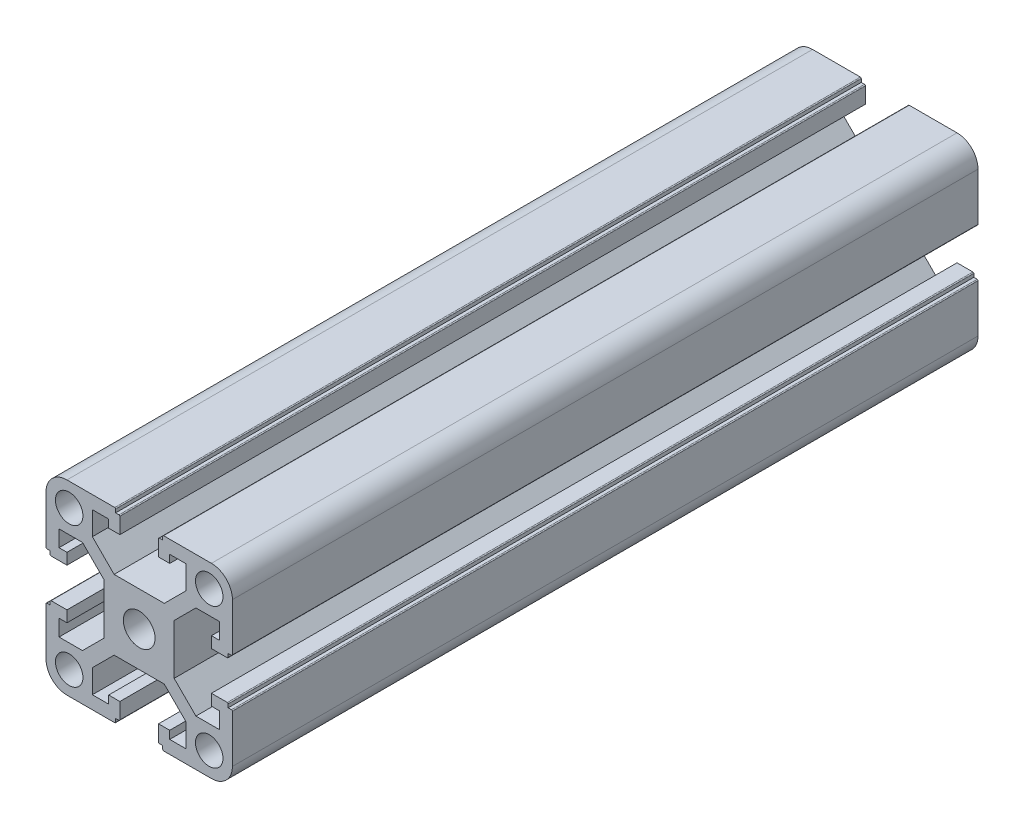
from build123d import *

# Parameters (mm, degrees)
SKETCH_1_R      = 2.95
SKETCH_1_R_2    = 3.4
EXTRUDE_1_DEPTH = 80


with BuildPart() as part:
    # 草图1 → 凸台-拉伸1 (new body, symmetric)
    with BuildSketch(Plane.XY.offset(50)):
        with BuildLine():
            Line((-1518.245004392, 3588.004280474), (-1518.245004392, 3582.975600817))
            Line((-1518.245004392, 3582.975600817), (-1522.916324736, 3578.304280474))
            Line((-1522.916324736, 3578.304280474), (-1533.673684048, 3578.304280474))
            Line((-1533.673684048, 3578.304280474), (-1538.345004392, 3582.975600817))
            Line((-1538.345004392, 3582.975600817), (-1538.345004392, 3588.004280474))
            Line((-1538.345004392, 3588.004280474), (-1534.845004392, 3588.004280474))
            Line((-1534.845004392, 3588.004280474), (-1534.845004392, 3586.304280474))
            Line((-1534.845004392, 3586.304280474), (-1532.445004392, 3586.304280474))
            Line((-1532.445004392, 3586.304280474), (-1532.445004392, 3589.704280474))
            ThreePointArc((-1532.445004392, 3589.704280474), (-1532.503583036, 3589.84570183), (-1532.645004392, 3589.904280474))
            Line((-1532.645004392, 3589.904280474), (-1533.345004392, 3589.904280474))
            Line((-1533.345004392, 3589.904280474), (-1533.345004392, 3590.604280474))
            ThreePointArc((-1533.345004392, 3590.604280474), (-1533.403583036, 3590.74570183), (-1533.545004392, 3590.804280474))
            Line((-1533.545004392, 3590.804280474), (-1543.795004392, 3590.804280474))
            ThreePointArc((-1543.795004392, 3590.804280474), (-1546.976984907, 3589.486260989), (-1548.295004392, 3586.304280474))
            Line((-1548.295004392, 3586.304280474), (-1548.295004392, 3576.054280474))
            ThreePointArc((-1548.295004392, 3576.054280474), (-1548.236425748, 3575.912859117), (-1548.095004392, 3575.854280474))
            Line((-1548.095004392, 3575.854280474), (-1547.395004392, 3575.854280474))
            Line((-1547.395004392, 3575.854280474), (-1547.395004392, 3575.154280474))
            ThreePointArc((-1547.395004392, 3575.154280474), (-1547.336425748, 3575.012859117), (-1547.195004392, 3574.954280474))
            Line((-1547.195004392, 3574.954280474), (-1543.795004392, 3574.954280474))
            Line((-1543.795004392, 3574.954280474), (-1543.795004392, 3577.354280474))
            Line((-1543.795004392, 3577.354280474), (-1545.495004392, 3577.354280474))
            Line((-1545.495004392, 3577.354280474), (-1545.495004392, 3580.854280474))
            Line((-1545.495004392, 3580.854280474), (-1540.466324736, 3580.854280474))
            Line((-1540.466324736, 3580.854280474), (-1535.795004392, 3576.18296013))
            Line((-1535.795004392, 3576.18296013), (-1535.795004392, 3565.425600817))
            Line((-1535.795004392, 3565.425600817), (-1540.466324736, 3560.754280474))
            Line((-1540.466324736, 3560.754280474), (-1545.495004392, 3560.754280474))
            Line((-1545.495004392, 3560.754280474), (-1545.495004392, 3564.254280474))
            Line((-1545.495004392, 3564.254280474), (-1543.795004392, 3564.254280474))
            Line((-1543.795004392, 3564.254280474), (-1543.795004392, 3566.654280474))
            Line((-1543.795004392, 3566.654280474), (-1547.195004392, 3566.654280474))
            ThreePointArc((-1547.195004392, 3566.654280474), (-1547.336425748, 3566.59570183), (-1547.395004392, 3566.454280474))
            Line((-1547.395004392, 3566.454280474), (-1547.395004392, 3565.754280474))
            Line((-1547.395004392, 3565.754280474), (-1548.095004392, 3565.754280474))
            ThreePointArc((-1548.095004392, 3565.754280474), (-1548.236425748, 3565.69570183), (-1548.295004392, 3565.554280474))
            Line((-1548.295004392, 3565.554280474), (-1548.295004392, 3555.304280474))
            ThreePointArc((-1548.295004392, 3555.304280474), (-1546.976984907, 3552.122299958), (-1543.795004392, 3550.804280474))
            Line((-1543.795004392, 3550.804280474), (-1533.545004392, 3550.804280474))
            ThreePointArc((-1533.545004392, 3550.804280474), (-1533.403583036, 3550.862859117), (-1533.345004392, 3551.004280474))
            Line((-1533.345004392, 3551.004280474), (-1533.345004392, 3551.704280474))
            Line((-1533.345004392, 3551.704280474), (-1532.645004392, 3551.704280474))
            ThreePointArc((-1532.645004392, 3551.704280474), (-1532.503583036, 3551.762859117), (-1532.445004392, 3551.904280474))
            Line((-1532.445004392, 3551.904280474), (-1532.445004392, 3555.304280474))
            Line((-1532.445004392, 3555.304280474), (-1534.845004392, 3555.304280474))
            Line((-1534.845004392, 3555.304280474), (-1534.845004392, 3553.604280474))
            Line((-1534.845004392, 3553.604280474), (-1538.345004392, 3553.604280474))
            Line((-1538.345004392, 3553.604280474), (-1538.345004392, 3558.63296013))
            Line((-1538.345004392, 3558.63296013), (-1533.673684048, 3563.304280474))
            Line((-1533.673684048, 3563.304280474), (-1522.916324736, 3563.304280474))
            Line((-1522.916324736, 3563.304280474), (-1518.245004392, 3558.63296013))
            Line((-1518.245004392, 3558.63296013), (-1518.245004392, 3553.604280474))
            Line((-1518.245004392, 3553.604280474), (-1521.745004392, 3553.604280474))
            Line((-1521.745004392, 3553.604280474), (-1521.745004392, 3555.304280474))
            Line((-1521.745004392, 3555.304280474), (-1524.145004392, 3555.304280474))
            Line((-1524.145004392, 3555.304280474), (-1524.145004392, 3551.904280474))
            ThreePointArc((-1524.145004392, 3551.904280474), (-1524.086425748, 3551.762859117), (-1523.945004392, 3551.704280474))
            Line((-1523.945004392, 3551.704280474), (-1523.245004392, 3551.704280474))
            Line((-1523.245004392, 3551.704280474), (-1523.245004392, 3551.004280474))
            ThreePointArc((-1523.245004392, 3551.004280474), (-1523.186425748, 3550.862859117), (-1523.045004392, 3550.804280474))
            Line((-1523.045004392, 3550.804280474), (-1512.795004392, 3550.804280474))
            ThreePointArc((-1512.795004392, 3550.804280474), (-1509.613023877, 3552.122299958), (-1508.295004392, 3555.304280474))
            Line((-1508.295004392, 3555.304280474), (-1508.295004392, 3565.554280474))
            ThreePointArc((-1508.295004392, 3565.554280474), (-1508.353583036, 3565.69570183), (-1508.495004392, 3565.754280474))
            Line((-1508.495004392, 3565.754280474), (-1509.195004392, 3565.754280474))
            Line((-1509.195004392, 3565.754280474), (-1509.195004392, 3566.454280474))
            ThreePointArc((-1509.195004392, 3566.454280474), (-1509.253583036, 3566.59570183), (-1509.395004392, 3566.654280474))
            Line((-1509.395004392, 3566.654280474), (-1512.795004392, 3566.654280474))
            Line((-1512.795004392, 3566.654280474), (-1512.795004392, 3564.254280474))
            Line((-1512.795004392, 3564.254280474), (-1511.095004392, 3564.254280474))
            Line((-1511.095004392, 3564.254280474), (-1511.095004392, 3560.754280474))
            Line((-1511.095004392, 3560.754280474), (-1516.123684048, 3560.754280474))
            Line((-1516.123684048, 3560.754280474), (-1520.795004392, 3565.425600817))
            Line((-1520.795004392, 3565.425600817), (-1520.795004392, 3576.18296013))
            Line((-1520.795004392, 3576.18296013), (-1516.123684048, 3580.854280474))
            Line((-1516.123684048, 3580.854280474), (-1511.095004392, 3580.854280474))
            Line((-1511.095004392, 3580.854280474), (-1511.095004392, 3577.354280474))
            Line((-1511.095004392, 3577.354280474), (-1512.795004392, 3577.354280474))
            Line((-1512.795004392, 3577.354280474), (-1512.795004392, 3574.954280474))
            Line((-1512.795004392, 3574.954280474), (-1509.395004392, 3574.954280474))
            ThreePointArc((-1509.395004392, 3574.954280474), (-1509.253583036, 3575.012859117), (-1509.195004392, 3575.154280474))
            Line((-1509.195004392, 3575.154280474), (-1509.195004392, 3575.854280474))
            Line((-1509.195004392, 3575.854280474), (-1508.495004392, 3575.854280474))
            ThreePointArc((-1508.495004392, 3575.854280474), (-1508.353583036, 3575.912859117), (-1508.295004392, 3576.054280474))
            Line((-1508.295004392, 3576.054280474), (-1508.295004392, 3586.304280474))
            ThreePointArc((-1508.295004392, 3586.304280474), (-1509.613023877, 3589.486260989), (-1512.795004392, 3590.804280474))
            Line((-1512.795004392, 3590.804280474), (-1523.045004392, 3590.804280474))
            ThreePointArc((-1523.045004392, 3590.804280474), (-1523.186425748, 3590.74570183), (-1523.245004392, 3590.604280474))
            Line((-1523.245004392, 3590.604280474), (-1523.245004392, 3589.904280474))
            Line((-1523.245004392, 3589.904280474), (-1523.945004392, 3589.904280474))
            ThreePointArc((-1523.945004392, 3589.904280474), (-1524.086425748, 3589.84570183), (-1524.145004392, 3589.704280474))
            Line((-1524.145004392, 3589.704280474), (-1524.145004392, 3586.304280474))
            Line((-1524.145004392, 3586.304280474), (-1521.745004392, 3586.304280474))
            Line((-1521.745004392, 3586.304280474), (-1521.745004392, 3588.004280474))
            Line((-1521.745004392, 3588.004280474), (-1518.245004392, 3588.004280474))
        make_face()
        with Locations((-1513.270004392, 3555.779280474)):
            Circle(SKETCH_1_R, mode=Mode.SUBTRACT)
        with Locations((-1528.295004392, 3570.804280474)):
            Circle(SKETCH_1_R_2, mode=Mode.SUBTRACT)
        with Locations((-1513.270004392, 3585.829280474)):
            Circle(SKETCH_1_R, mode=Mode.SUBTRACT)
        with Locations((-1543.320004392, 3585.829280474)):
            Circle(SKETCH_1_R, mode=Mode.SUBTRACT)
        with Locations((-1543.320004392, 3555.779280474)):
            Circle(SKETCH_1_R, mode=Mode.SUBTRACT)
    extrude(amount=EXTRUDE_1_DEPTH, both=True)


solid = part.part
